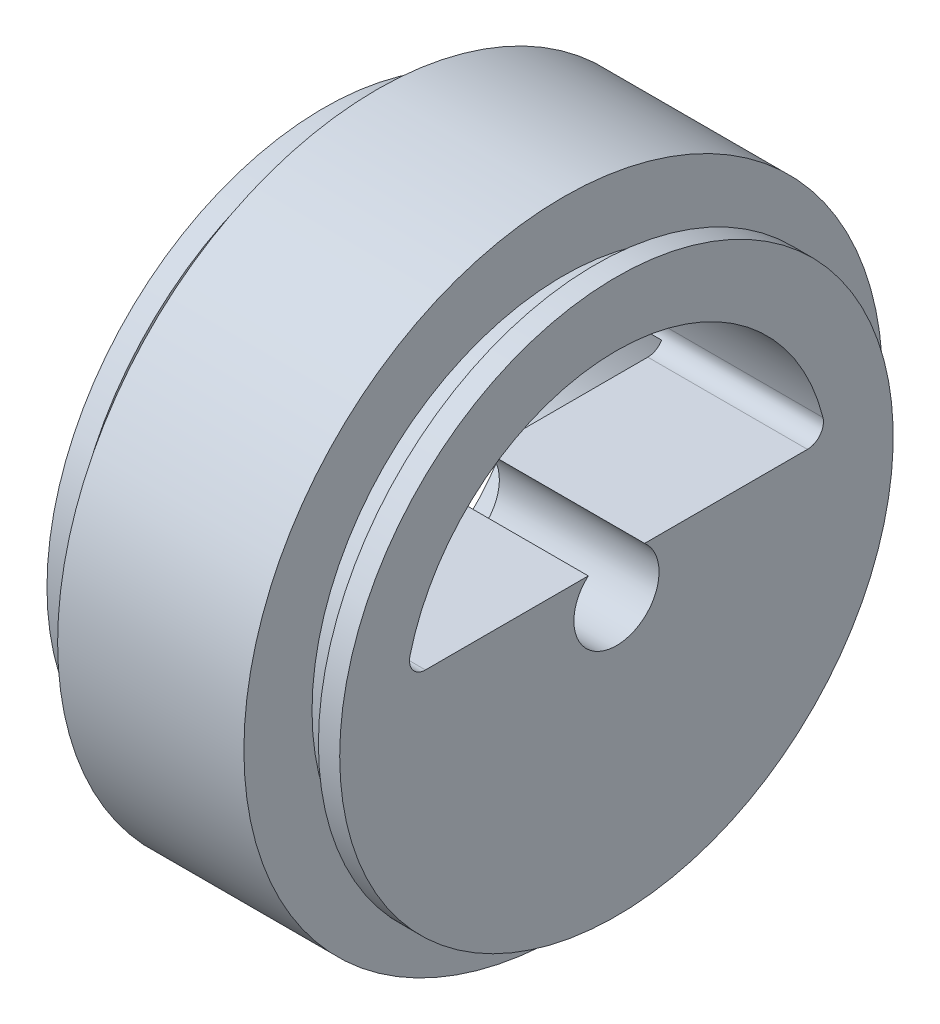
from build123d import *

# Parameters (mm, degrees)
EXTRUSION1_DEPTH = 28.5


with BuildPart() as part:
    # Esquisse1 → Révolution1 (revolve)
    with BuildSketch(Plane.XY):
        Polygon((-2.5, 19.6), (-2.5, 26), (-0.5, 26), (-0.5, 23.6), (2.5, 23.6), (2.5, 30), (20, 30), (20, 23.6), (23, 23.6), (23, 26), (25, 26), (25, 4), (10, 4), (10, 19.6), align=None)
    revolve(axis=Axis((10, 0, 0), (1, 0, 0)))

    # Esquisse2 → Extrusion1 (cut, through all)
    with BuildSketch(Plane(origin=(25, 0, 0), x_dir=(0, 0, -1), z_dir=(1, 0, 0))):
        with BuildLine():
            Line((17.944358445, 3), (-17.944358445, 3))
            ThreePointArc((-17.944358445, 3), (-19.127003214, 3.577312972), (-19.399306427, 4.864864865))
            ThreePointArc((-19.399306427, 4.864864865), (0, 20), (19.399306427, 4.864864865))
            ThreePointArc((19.399306427, 4.864864865), (19.127003214, 3.577312972), (17.944358445, 3))
        make_face()
    extrude(amount=-EXTRUSION1_DEPTH, mode=Mode.SUBTRACT)


solid = part.part
